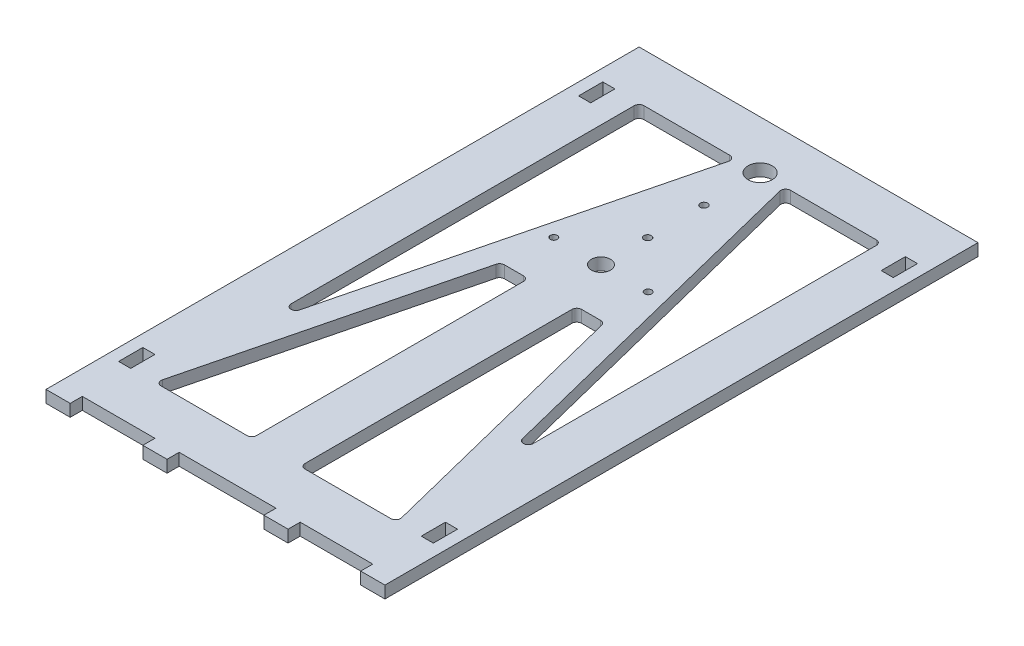
from build123d import *

# Parameters (mm, degrees)
SKETCH1_W         = 6.35
SKETCH1_H         = 12.7
SKETCH1_R         = 1.8542
SKETCH1_R_2       = 1.93499994
SKETCH1_R_3       = 5.000000033
SKETCH1_R_4       = 6.35
SKETCH1_W_2       = 12.7
SKETCH1_H_2       = 6.35
FRONT_PANEL_DEPTH = 6.35
FILLET1_R         = 2.54


with BuildPart() as part:
    # Sketch1 → Front Panel (new body)
    with BuildSketch(Plane(origin=(0, 0, 0), x_dir=(1, 0, 0), z_dir=(0, 1, 0))):
        Polygon((0, 304.8), (0, 0), (12.7, 0), (50.8, 0), (63.5, 0), (114.3, 0), (127, 0), (165.1, 0), (177.8, 0), (177.8, 304.8), align=None)
        with Locations((9.525, 31.75)):
            Rectangle(SKETCH1_W, SKETCH1_H, mode=Mode.SUBTRACT)
        Polygon((76.2, 25.4), (25.4, 25.4), (61.675000031, 170.500000122), (76.2, 170.500000122), align=None, mode=Mode.SUBTRACT)
        with Locations((168.275, 31.75)):
            Rectangle(SKETCH1_W, SKETCH1_H, mode=Mode.SUBTRACT)
        Polygon((101.6, 25.4), (101.6, 170.500000122), (116.124999969, 170.500000122), (152.4, 25.4), align=None, mode=Mode.SUBTRACT)
        Polygon((25.4, 279.4), (76.2, 279.4), (25.4, 76.2), align=None, mode=Mode.SUBTRACT)
        with Locations((64.14999997, 195.900000122)):
            Circle(SKETCH1_R, mode=Mode.SUBTRACT)
        with Locations((88.9, 220.400000144)):
            Circle(SKETCH1_R_2, mode=Mode.SUBTRACT)
        with Locations((9.525, 273.05)):
            Rectangle(SKETCH1_W, SKETCH1_H, mode=Mode.SUBTRACT)
        with Locations((88.9, 249.900000072)):
            Circle(SKETCH1_R_2, mode=Mode.SUBTRACT)
        Polygon((152.4, 76.2), (101.6, 279.4), (152.4, 279.4), align=None, mode=Mode.SUBTRACT)
        with Locations((88.9, 195.900000122)):
            Circle(SKETCH1_R_3, mode=Mode.SUBTRACT)
        with Locations((113.65000003, 195.900000122)):
            Circle(SKETCH1_R, mode=Mode.SUBTRACT)
        with Locations((88.9, 279.4)):
            Circle(SKETCH1_R_4, mode=Mode.SUBTRACT)
        with Locations((168.275, 273.05)):
            Rectangle(SKETCH1_W, SKETCH1_H, mode=Mode.SUBTRACT)
        with Locations((6.35, -3.175)):
            Rectangle(SKETCH1_W_2, SKETCH1_H_2)
        with Locations((57.15, -3.175)):
            Rectangle(SKETCH1_W_2, SKETCH1_H_2)
        with Locations((120.65, -3.175)):
            Rectangle(SKETCH1_W_2, SKETCH1_H_2)
        with Locations((171.45, -3.175)):
            Rectangle(SKETCH1_W_2, SKETCH1_H_2)
    extrude(amount=FRONT_PANEL_DEPTH)

    # Fillet1
    fillet1_edges = [part.edges().sort_by_distance(p)[0] for p in [
        (76.2, 3.175, -170.500000122),
        (61.675000031, 3.175, -170.500000122),
        (25.4, 3.175, -25.4),
        (76.2, 3.175, -25.4),
        (152.4, 3.175, -25.4),
        (116.124999969, 3.175, -170.500000122),
        (101.6, 3.175, -170.500000122),
        (101.6, 3.175, -25.4),
        (152.4, 3.175, -279.4),
        (101.6, 3.175, -279.4),
        (152.4, 3.175, -76.2),
        (76.2, 3.175, -279.4),
        (25.4, 3.175, -279.4),
        (25.4, 3.175, -76.2),
    ]]
    fillet(fillet1_edges, radius=FILLET1_R)


solid = part.part
